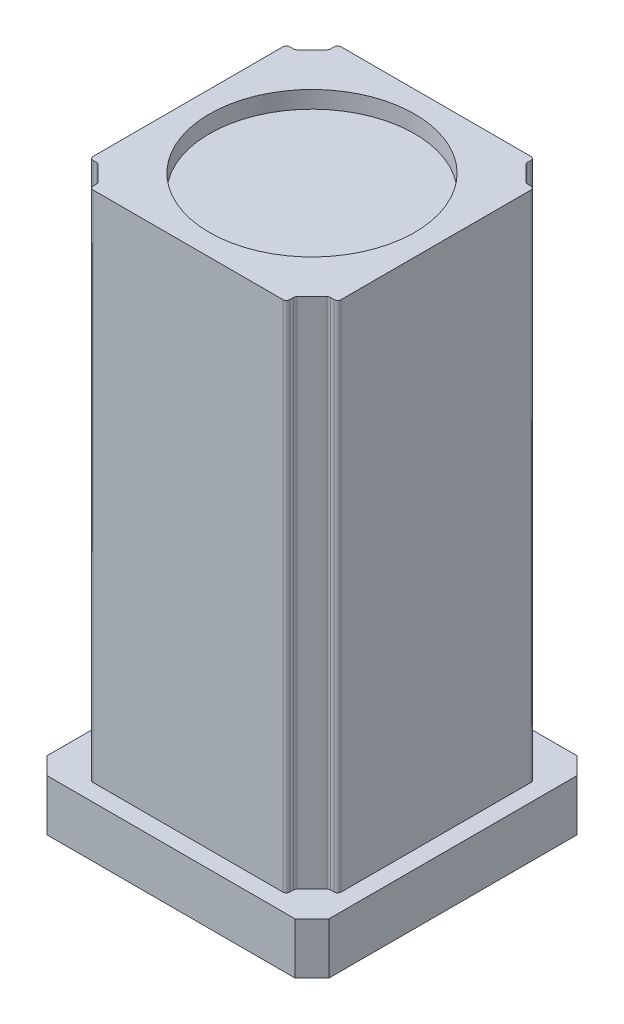
from build123d import *

# Parameters (mm, degrees)
BOSS_EXTRUDE1_DEPTH = 30
BOSS_EXTRUDE2_DEPTH = 300
SKETCH3_R           = 60
CUT_EXTRUDE1_DEPTH  = 10
FILLET1_R           = 2


with BuildPart() as part:
    # Sketch1 → Boss-Extrude1 (new body)
    with BuildSketch(Plane(origin=(0, 0, 0), x_dir=(1, 0, 0), z_dir=(0, 1, 0))):
        Polygon((-82.5, 72.5), (-72.5, 82.5), (72.5, 82.5), (82.5, 72.5), (82.5, -72.5), (72.5, -82.5), (-72.5, -82.5), (-82.5, -72.5), align=None)
    extrude(amount=BOSS_EXTRUDE1_DEPTH)

    # Sketch2 → Boss-Extrude2 (add)
    with BuildSketch(Plane(origin=(0, 30, 0), x_dir=(1, 0, 0), z_dir=(0, 1, 0))):
        Polygon((72.5, 57.5), (67.5, 57.5), (57.5, 67.5), (57.5, 72.5), (-57.5, 72.5), (-57.5, 67.5), (-67.5, 57.5), (-72.5, 57.5), (-72.5, -57.5), (-67.5, -57.5), (-57.5, -67.5), (-57.5, -72.5), (57.5, -72.5), (57.5, -67.5), (67.5, -57.5), (72.5, -57.5), align=None)
    extrude(amount=BOSS_EXTRUDE2_DEPTH)

    # Sketch3 → Cut-Extrude1 (cut)
    with BuildSketch(Plane(origin=(0, 330, 0), x_dir=(1, 0, 0), z_dir=(0, 1, 0))):
        Circle(SKETCH3_R)
    extrude(amount=-CUT_EXTRUDE1_DEPTH, mode=Mode.SUBTRACT)

    # Fillet1
    fillet1_edges = [part.edges().sort_by_distance(p)[0] for p in [
        (72.5, 180, 57.5),
        (72.5, 180, -57.5),
        (67.5, 180, -57.5),
        (57.5, 180, -67.5),
        (57.5, 180, -72.5),
        (-57.5, 180, -72.5),
        (-57.5, 180, -67.5),
        (-67.5, 180, -57.5),
        (-72.5, 180, -57.5),
        (-72.5, 180, 57.5),
        (-67.5, 180, 57.5),
        (-57.5, 180, 67.5),
        (-57.5, 180, 72.5),
        (57.5, 180, 72.5),
        (57.5, 180, 67.5),
        (67.5, 180, 57.5),
    ]]
    fillet(fillet1_edges, radius=FILLET1_R)


solid = part.part
